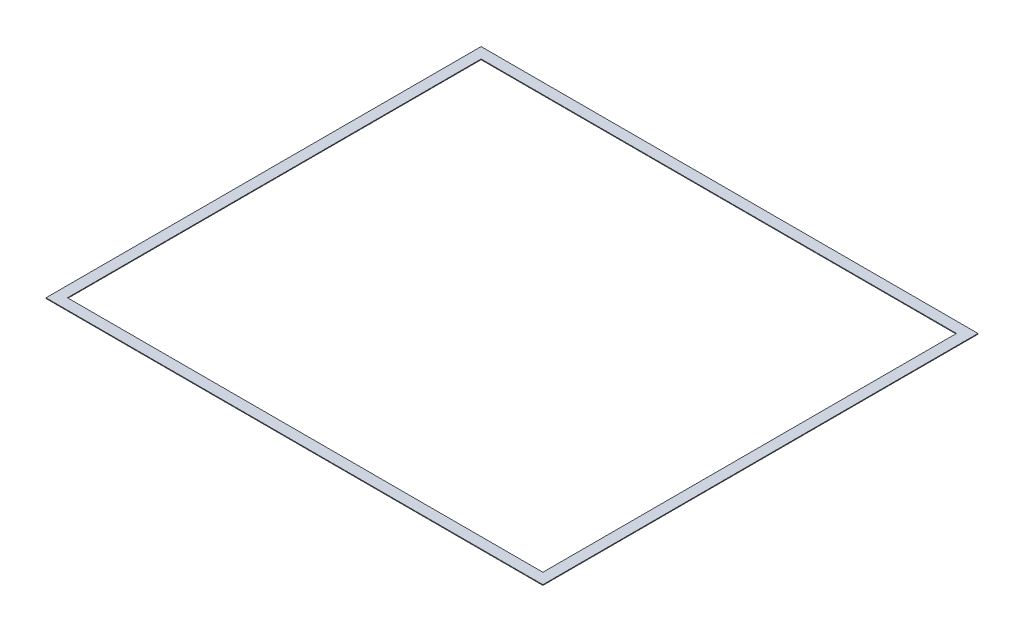
from build123d import *

# Parameters (mm, degrees)
SKETCH1_W           = 2349.5
SKETCH1_H           = 2057.4
SKETCH1_W_2         = 2247.9
SKETCH1_H_2         = 1955.8
BOSS_EXTRUDE1_DEPTH = 3.175


with BuildPart() as part:
    # Sketch1 → Boss-Extrude1 (new body)
    with BuildSketch(Plane(origin=(0, 0, 0), x_dir=(1, 0, 0), z_dir=(0, 1, 0))):
        Rectangle(SKETCH1_W, SKETCH1_H)
        Rectangle(SKETCH1_W_2, SKETCH1_H_2, mode=Mode.SUBTRACT)
    extrude(amount=BOSS_EXTRUDE1_DEPTH)


solid = part.part
